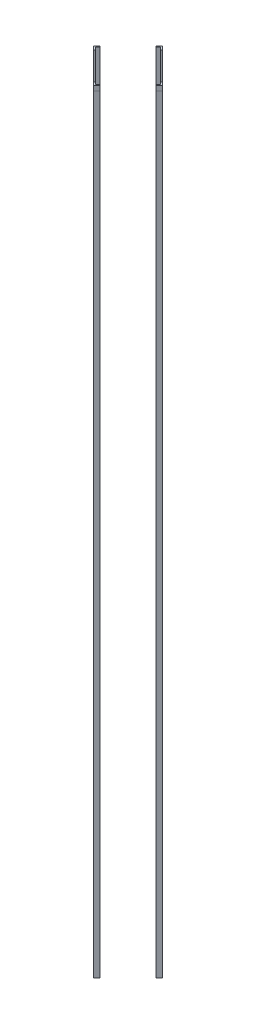
from build123d import *

# Parameters (mm, degrees)
BOSS_EXTRUDE1_DEPTH   = 2133.6
BOSS_EXTRUDE1_2_DEPTH = 2133.6
BOSS_EXTRUDE1_3_DEPTH = 2133.6
BOSS_EXTRUDE1_4_DEPTH = 2133.6
SKETCH3_W             = 12.7
SKETCH3_H             = 12.7
BOSS_EXTRUDE2_DEPTH   = 0.0254
SKETCH4_W             = 12.7
SKETCH4_H             = 12.7
BOSS_EXTRUDE3_DEPTH   = 0.0254


with BuildPart() as part:
    # Sketch2 → Boss-Extrude1 (new body)
    with BuildSketch(Plane(origin=(0, 0, 0), x_dir=(1, 0, 0), z_dir=(0, 1, 0))):
        Polygon((0, 94.77428536), (-8.980256121, 85.794029239), (-6.735192091, 83.548965209), (0, 90.2841573), (6.735192091, 83.548965209), (8.980256121, 85.794029239), align=None)
    extrude(amount=BOSS_EXTRUDE1_DEPTH)


with BuildPart() as body_2:
    # Sketch2 → Boss-Extrude1 2 (new body)
    with BuildSketch(Plane(origin=(0, 0, 0), x_dir=(1, 0, 0), z_dir=(0, 1, 0))):
        Polygon((94.77428536, 0), (85.794029239, 8.980256121), (83.548965209, 6.735192091), (90.2841573, 0), (83.548965209, -6.735192091), (85.794029239, -8.980256121), align=None)
    extrude(amount=BOSS_EXTRUDE1_2_DEPTH)

    # Sketch4 → Boss-Extrude3 (add)
    with BuildSketch(Plane(origin=(47.38714268, 0, 47.38714268), x_dir=(0.707106781, 0, -0.707106781), z_dir=(0.707106781, 0, 0.707106781))):
        with Locations((60.66553986, 2127.25)):
            Rectangle(SKETCH4_W, SKETCH4_H)
    extrude(amount=BOSS_EXTRUDE3_DEPTH)


with BuildPart() as body_3:
    # Sketch2 → Boss-Extrude1 3 (new body)
    with BuildSketch(Plane(origin=(0, 0, 0), x_dir=(1, 0, 0), z_dir=(0, 1, 0))):
        Polygon((0, -94.77428536), (8.980256121, -85.794029239), (6.735192091, -83.548965209), (0, -90.2841573), (-6.735192091, -83.548965209), (-8.980256121, -85.794029239), align=None)
    extrude(amount=BOSS_EXTRUDE1_3_DEPTH)

    # Sketch3 → Boss-Extrude2 (add)
    with BuildSketch(Plane(origin=(47.38714268, 0, 47.38714268), x_dir=(0.707106781, 0, -0.707106781), z_dir=(0.707106781, 0, 0.707106781))):
        with Locations((-60.66553986, 2127.25)):
            Rectangle(SKETCH3_W, SKETCH3_H)
    extrude(amount=BOSS_EXTRUDE2_DEPTH)


with BuildPart() as body_4:
    # Sketch2 → Boss-Extrude1 4 (new body)
    with BuildSketch(Plane(origin=(0, 0, 0), x_dir=(1, 0, 0), z_dir=(0, 1, 0))):
        Polygon((-94.77428536, 0), (-85.794029239, -8.980256121), (-83.548965209, -6.735192091), (-90.2841573, 0), (-83.548965209, 6.735192091), (-85.794029239, 8.980256121), align=None)
    extrude(amount=BOSS_EXTRUDE1_4_DEPTH)


solid = Compound([part.part, body_2.part, body_3.part, body_4.part])
